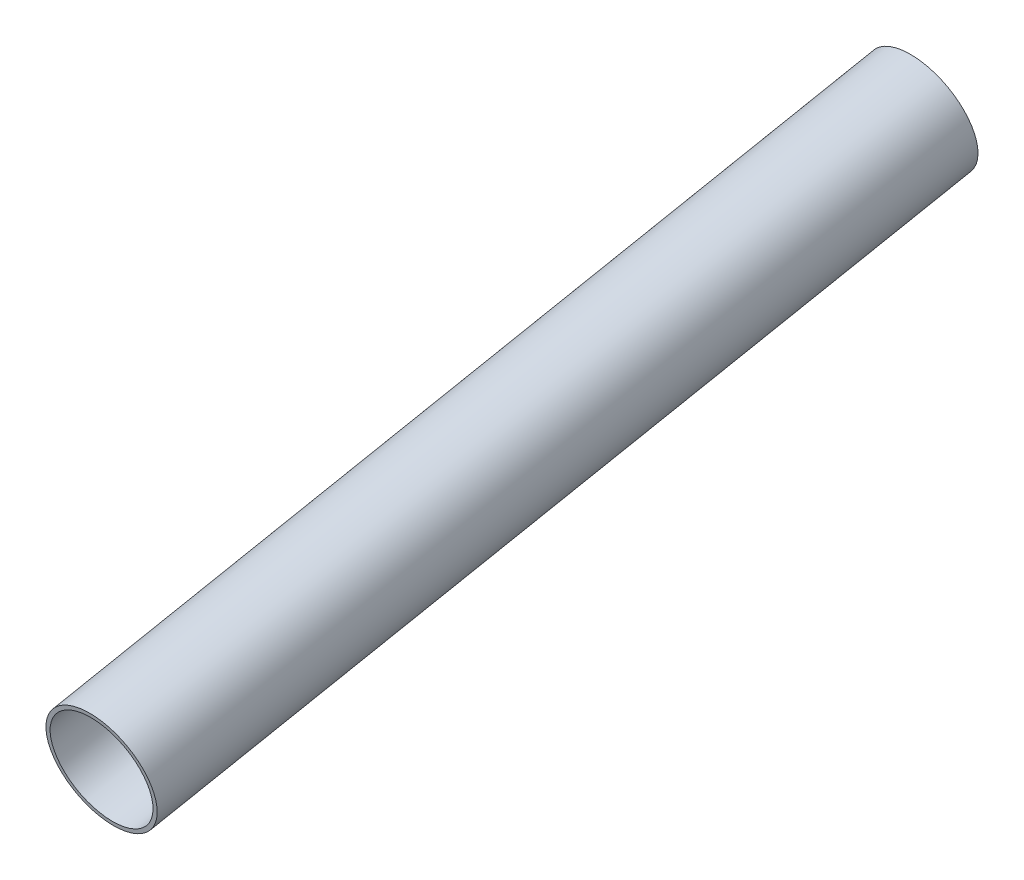
from build123d import *

# Parameters (mm, degrees)
SKETCH1_R                = 9.525
SKETCH1_R_2              = 8.8138
BOSS_EXTRUDE1_DEPTH      = 51.117501
BOSS_EXTRUDE1_DEPTH_BACK = 92.71


with BuildPart() as part:
    # Sketch1 → Boss-Extrude1 (new body, two sides)
    with BuildSketch(Plane(origin=(-4.320902972, 462.859999428, 1874.607036139), x_dir=(0.999960038, -0.001161747, 0.008864103), z_dir=(-0.008916207, -0.201755507, 0.979395332))) as boss_extrude1_sk:
        Circle(SKETCH1_R)
        Circle(SKETCH1_R_2, mode=Mode.SUBTRACT)
    extrude(amount=BOSS_EXTRUDE1_DEPTH)
    extrude(boss_extrude1_sk.sketch, amount=-BOSS_EXTRUDE1_DEPTH_BACK)


solid = part.part
